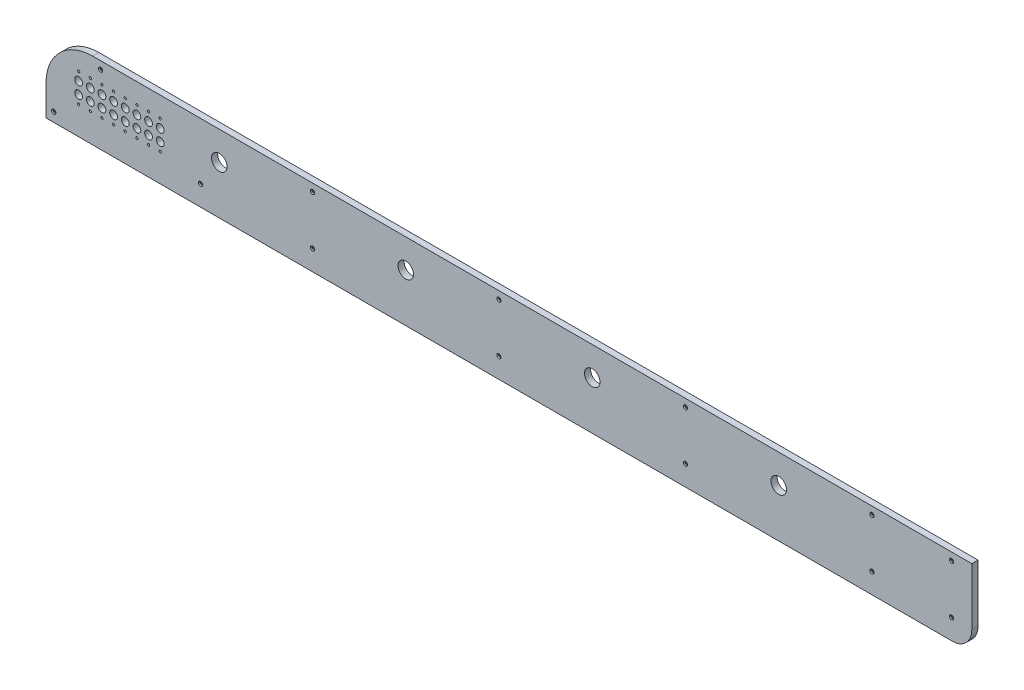
from build123d import *

# Parameters (mm, degrees)
BOSS_EXTRU_1_DEPTH                                 = 8
ESQUISSE3_R                                        = 1.5
ESQUISSE3_R_2                                      = 5
ENL_V_MAT_EXTRU_1_DEPTH                            = 9
ESQUISSE4_R                                        = 10
ENL_V_MAT_EXTRU_2_DEPTH                            = 9
CHAMBRAGE_POUR_VIS_T_TE_CYLINDRIQUE_CO_D           = 3
CHAMBRAGE_POUR_VIS_T_TE_CYLINDRIQUE_CO_CBORE_D     = 5.5
CHAMBRAGE_POUR_VIS_T_TE_CYLINDRIQUE_CO_CBORE_DEPTH = 2


with BuildPart() as part:
    # Esquisse1 → Boss.-Extru.1 (new body)
    with BuildSketch(Plane.XY):
        with BuildLine():
            Line((938.5, 261), (-193, 261))
            ThreePointArc((-193, 261), (-235.426406871, 243.426406871), (-253, 201))
            Line((-253, 201), (-253, 162))
            Line((-253, 162), (913.5, 162))
            ThreePointArc((913.5, 162), (931.17766953, 169.32233047), (938.5, 187))
            Line((938.5, 187), (938.5, 261))
        make_face()
    extrude(amount=BOSS_EXTRU_1_DEPTH)

    # Esquisse3 → Enlèv. mat.-Extru.1 (cut, through all)
    with BuildSketch(Plane.XY.offset(8)):
        with Locations((-211, 198)):
            Circle(ESQUISSE3_R)
        with Locations((-211, 209)):
            Circle(ESQUISSE3_R_2)
        with Locations((-211, 224)):
            Circle(ESQUISSE3_R_2)
        with Locations((-211, 235)):
            Circle(ESQUISSE3_R)
        with Locations((-196, 209)):
            Circle(ESQUISSE3_R_2)
        with Locations((-196, 198)):
            Circle(ESQUISSE3_R)
        with Locations((-196, 224)):
            Circle(ESQUISSE3_R_2)
        with Locations((-196, 235)):
            Circle(ESQUISSE3_R)
        with Locations((-181, 209)):
            Circle(ESQUISSE3_R_2)
        with Locations((-181, 198)):
            Circle(ESQUISSE3_R)
        with Locations((-181, 224)):
            Circle(ESQUISSE3_R_2)
        with Locations((-181, 235)):
            Circle(ESQUISSE3_R)
        with Locations((-166, 209)):
            Circle(ESQUISSE3_R_2)
        with Locations((-166, 198)):
            Circle(ESQUISSE3_R)
        with Locations((-166, 224)):
            Circle(ESQUISSE3_R_2)
        with Locations((-166, 235)):
            Circle(ESQUISSE3_R)
        with Locations((-151, 209)):
            Circle(ESQUISSE3_R_2)
        with Locations((-151, 198)):
            Circle(ESQUISSE3_R)
        with Locations((-151, 224)):
            Circle(ESQUISSE3_R_2)
        with Locations((-151, 235)):
            Circle(ESQUISSE3_R)
        with Locations((-136, 209)):
            Circle(ESQUISSE3_R_2)
        with Locations((-136, 198)):
            Circle(ESQUISSE3_R)
        with Locations((-136, 224)):
            Circle(ESQUISSE3_R_2)
        with Locations((-136, 235)):
            Circle(ESQUISSE3_R)
        with Locations((-121, 209)):
            Circle(ESQUISSE3_R_2)
        with Locations((-121, 198)):
            Circle(ESQUISSE3_R)
        with Locations((-121, 224)):
            Circle(ESQUISSE3_R_2)
        with Locations((-121, 235)):
            Circle(ESQUISSE3_R)
        with Locations((-106, 209)):
            Circle(ESQUISSE3_R_2)
        with Locations((-106, 198)):
            Circle(ESQUISSE3_R)
        with Locations((-106, 224)):
            Circle(ESQUISSE3_R_2)
        with Locations((-106, 235)):
            Circle(ESQUISSE3_R)
    extrude(amount=-ENL_V_MAT_EXTRU_1_DEPTH, mode=Mode.SUBTRACT)

    # Esquisse4 → Enlèv. mat.-Extru.2 (cut, through all)
    with BuildSketch(Plane.XY.offset(8)):
        with Locations((-30, 224)):
            Circle(ESQUISSE4_R)
        with Locations((210, 224)):
            Circle(ESQUISSE4_R)
        with Locations((450, 224)):
            Circle(ESQUISSE4_R)
        with Locations((690, 224)):
            Circle(ESQUISSE4_R)
    extrude(amount=-ENL_V_MAT_EXTRU_2_DEPTH, mode=Mode.SUBTRACT)

    # Chambrage pour vis à tête cylindrique courte six pans creux M31 (through all)
    with Locations(Plane.XY.offset(8)):
        with Locations((-54, 188), (90, 188), (330, 188), (570, 188), (810, 188), (912.5, 188), (912.5, 251), (810, 251), (570, 251), (330, 251), (90, 251), (-243, 174), (-182.768699819, 251)):
            CounterBoreHole(CHAMBRAGE_POUR_VIS_T_TE_CYLINDRIQUE_CO_D / 2, CHAMBRAGE_POUR_VIS_T_TE_CYLINDRIQUE_CO_CBORE_D / 2, CHAMBRAGE_POUR_VIS_T_TE_CYLINDRIQUE_CO_CBORE_DEPTH)


solid = part.part
